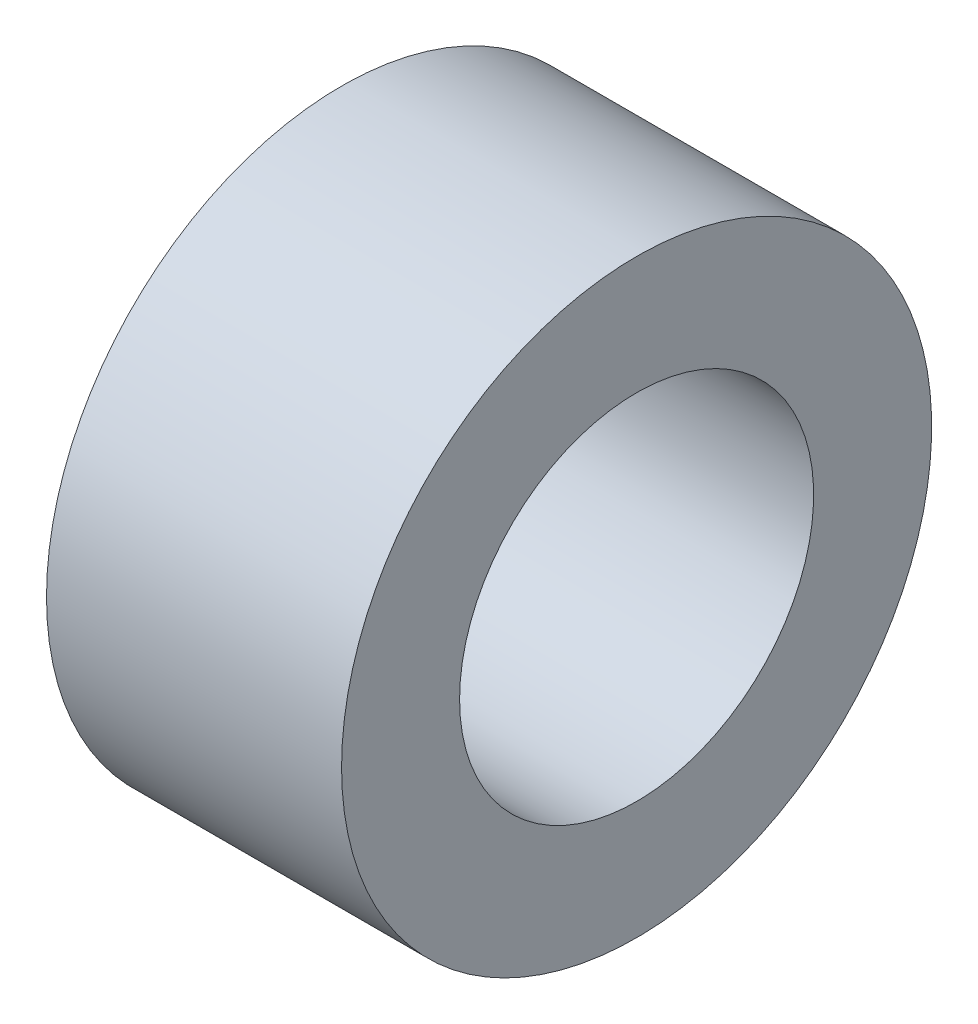
from build123d import *

# Parameters (mm, degrees)
SKETCH1_W = 5
SKETCH1_H = 2


with BuildPart() as part:
    # Sketch1 → Revolve1 (revolve)
    with BuildSketch(Plane.XY):
        with Locations((0, 4)):
            Rectangle(SKETCH1_W, SKETCH1_H)
    revolve(axis=Axis((-37.003163219, 0, 0), (1, 0, 0)))


solid = part.part
